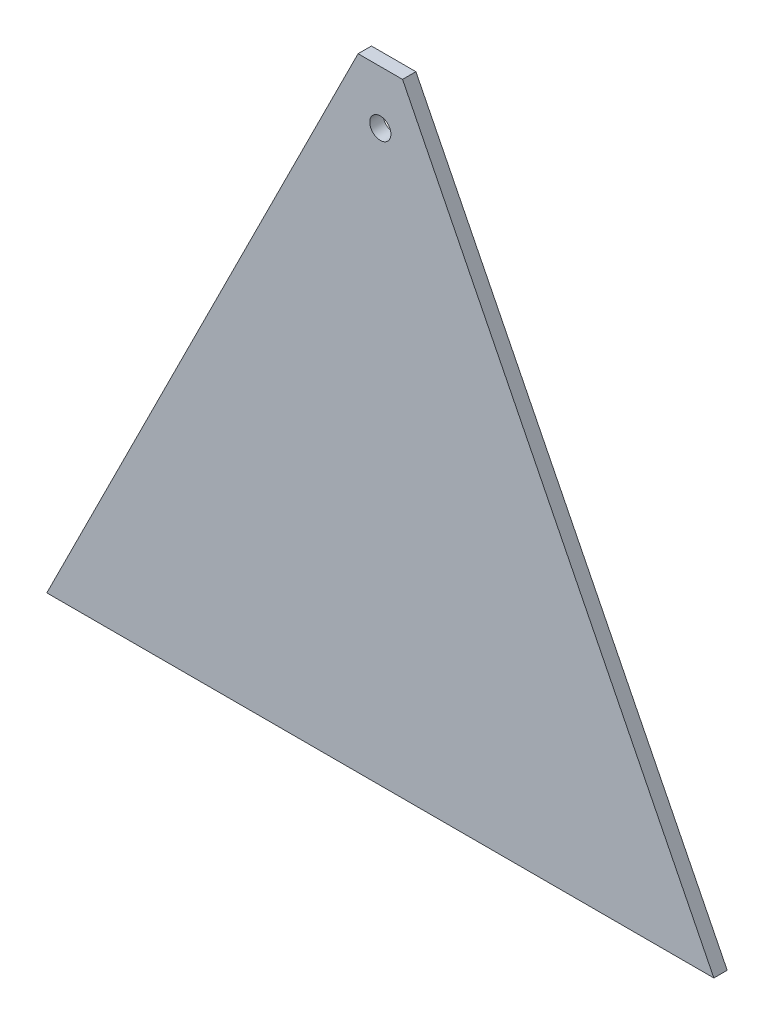
from build123d import *

# Parameters (mm, degrees)
SALIENTE_EXTRUIR1_DEPTH = 3
CROQUIS2_R              = 2.38125
CORTAR_EXTRUIR1_DEPTH   = 4


with BuildPart() as part:
    # Croquis1 → Saliente-Extruir1 (new body)
    with BuildSketch(Plane.XY):
        Polygon((75, 0), (-75, 0), (0, 150), align=None)
    extrude(amount=SALIENTE_EXTRUIR1_DEPTH)

    # Croquis2 → Cortar-Extruir1 (cut, through all)
    with BuildSketch(Plane.XY):
        with Locations((0, 128)):
            Circle(CROQUIS2_R)
        Polygon((5, 140), (0, 150), (-5, 140), align=None)
    extrude(amount=CORTAR_EXTRUIR1_DEPTH, mode=Mode.SUBTRACT)


solid = part.part
